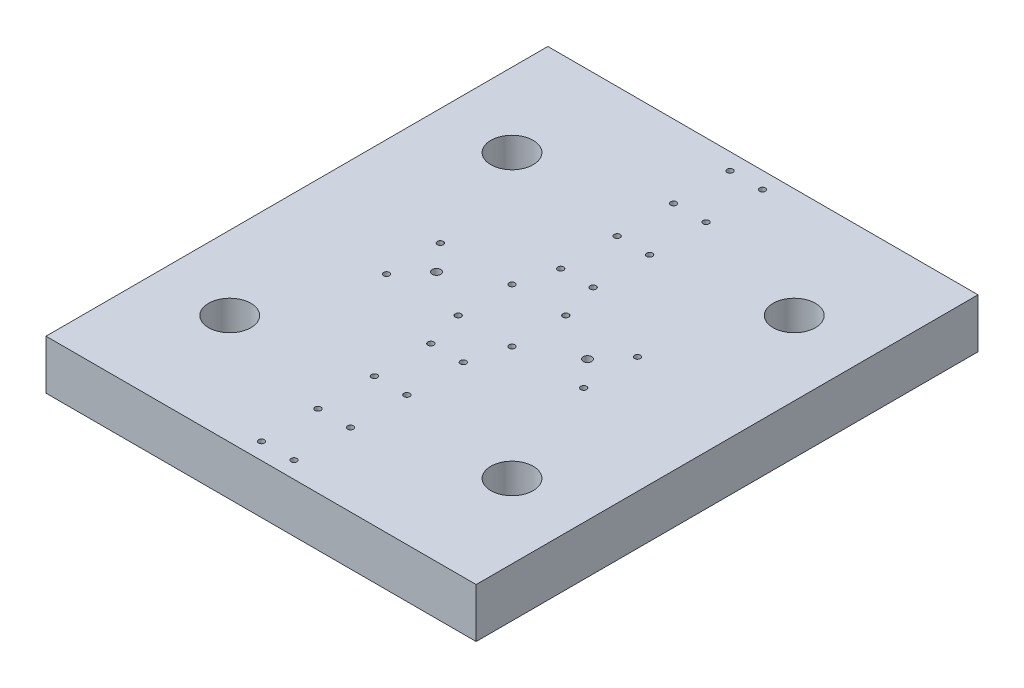
from build123d import *

# Parameters (mm, degrees)
SKETCH2_W                      = 304.8
SKETCH2_H                      = 355.6
MAINBASE_EXTRUDE_DEPTH         = 17.5
SKETCH3_R                      = 15
HOLES_POLE_DEPTH               = 36
M5X0_8_TAPPED_HOLE1_D          = 4.2
M5X0_8_TAPPED_HOLE2_D          = 4.2
M5X0_8_TAPPED_HOLE3_AT_2_COUNT = 2
M5X0_8_TAPPED_HOLE3_AT_2_PITCH = 15
M5X0_8_TAPPED_HOLE3_AT_3_COUNT = 2
M5X0_8_TAPPED_HOLE3_AT_3_PITCH = 57.008771255
M5X0_8_TAPPED_HOLE3_AT_4_COUNT = 2
M5X0_8_TAPPED_HOLE3_AT_4_PITCH = 55
M5X0_8_TAPPED_HOLE3_AT_5_COUNT = 2
M5X0_8_TAPPED_HOLE3_AT_5_PITCH = 115.974135047
M5X0_8_TAPPED_HOLE3_AT_6_COUNT = 2
M5X0_8_TAPPED_HOLE3_AT_6_PITCH = 115
SKETCH14_R                     = 3
CUT_EXTRUDE1_DEPTH             = 10


with BuildPart() as part:
    # Sketch2 → MainBase_Extrude (new body, symmetric)
    with BuildSketch(Plane(origin=(0, 0, 0), x_dir=(1, 0, 0), z_dir=(0, 1, 0))):
        Rectangle(SKETCH2_W, SKETCH2_H)
    extrude(amount=MAINBASE_EXTRUDE_DEPTH, both=True)

    # Sketch3 → Holes_Pole (cut, through all)
    with BuildSketch(Plane(origin=(0, 17.5, 0), x_dir=(1, 0, 0), z_dir=(0, 1, 0))):
        with Locations((-100, 100)):
            Circle(SKETCH3_R)
        with Locations((100, 100)):
            Circle(SKETCH3_R)
        with Locations((100, -100)):
            Circle(SKETCH3_R)
        with Locations((-100, -100)):
            Circle(SKETCH3_R)
    extrude(amount=-HOLES_POLE_DEPTH, mode=Mode.SUBTRACT)

    # M5x0.8 Tapped Hole1 (through all)
    with Locations(Plane(origin=(0, 17.5, 0), x_dir=(1, 0, 0), z_dir=(0, 1, 0))):
        with Locations((-69.85, 19.05), (-19.05, 19.05), (-19.05, -19.05), (-69.85, -19.05), (19.05, 19.05), (19.05, -19.05), (69.85, -19.05), (69.85, 19.05)):
            Hole(M5X0_8_TAPPED_HOLE1_D / 2)

    # M5x0.8 Tapped Hole2 (through all)
    with Locations(Plane(origin=(0, 17.5, 0), x_dir=(1, 0, 0), z_dir=(0, 1, 0))):
        with Locations((-11.5, -45.9918251), (11.5, -45.9918251), (11.5, -85.9918251), (-11.5, -85.9918251), (-11.5, -125.9918251), (11.5, -125.9918251), (-11.5, -165.9918251), (11.5, -165.9918251)):
            m5x0_8_tapped_hole2 = Hole(M5X0_8_TAPPED_HOLE2_D / 2)

    # Mirror1: M5x0.8 Tapped Hole2 across plane
    add(m5x0_8_tapped_hole2.mirror(Plane.XY), mode=Mode.SUBTRACT)

    # Sketch12 → M5x0.8 Tapped Hole3 (revolve, cut)
    with BuildSketch(Plane(origin=(-64.5, -17.5, -142.5), x_dir=(0, 0, -1), z_dir=(1, 0, 0))):
        Polygon((0, 0), (0, 13.6618073), (2.1, 12.4), (2.1, 0), align=None)
    m5x0_8_tapped_hole3 = revolve(axis=Axis((-64.5, -23.85, -142.5), (0, 1, 0)), mode=Mode.SUBTRACT)

    # M5x0.8 Tapped Hole3 at 2: M5x0.8 Tapped Hole3 ×2
    with Locations(*[(i * M5X0_8_TAPPED_HOLE3_AT_2_PITCH, 0, 0) for i in range(1, M5X0_8_TAPPED_HOLE3_AT_2_COUNT)]):
        add(m5x0_8_tapped_hole3, mode=Mode.SUBTRACT)

    # M5x0.8 Tapped Hole3 at 3: M5x0.8 Tapped Hole3 ×2
    with Locations(*[Vector(0.263117406, 0, 0.964763821) * (i * M5X0_8_TAPPED_HOLE3_AT_3_PITCH) for i in range(1, M5X0_8_TAPPED_HOLE3_AT_3_COUNT)]):
        add(m5x0_8_tapped_hole3, mode=Mode.SUBTRACT)

    # M5x0.8 Tapped Hole3 at 4: M5x0.8 Tapped Hole3 ×2
    with Locations(*[(0, 0, i * M5X0_8_TAPPED_HOLE3_AT_4_PITCH) for i in range(1, M5X0_8_TAPPED_HOLE3_AT_4_COUNT)]):
        add(m5x0_8_tapped_hole3, mode=Mode.SUBTRACT)

    # M5x0.8 Tapped Hole3 at 5: M5x0.8 Tapped Hole3 ×2
    with Locations(*[Vector(0.129339184, 0, 0.991600411) * (i * M5X0_8_TAPPED_HOLE3_AT_5_PITCH) for i in range(1, M5X0_8_TAPPED_HOLE3_AT_5_COUNT)]):
        add(m5x0_8_tapped_hole3, mode=Mode.SUBTRACT)

    # M5x0.8 Tapped Hole3 at 6: M5x0.8 Tapped Hole3 ×2
    with Locations(*[(0, 0, i * M5X0_8_TAPPED_HOLE3_AT_6_PITCH) for i in range(1, M5X0_8_TAPPED_HOLE3_AT_6_COUNT)]):
        add(m5x0_8_tapped_hole3, mode=Mode.SUBTRACT)

    # Mirror2: M5x0.8 Tapped Hole3 across plane
    add(m5x0_8_tapped_hole3.mirror(Plane.XY), mode=Mode.SUBTRACT)

    # Mirror2 copy 1 sketch → Mirror2 copy 1 (revolve, cut)
    with BuildSketch(Plane(origin=(-49.5, -17.5, 142.5), x_dir=(0, 0, 1), z_dir=(1, 0, 0))):
        Polygon((0, 0), (0, -13.6618073), (2.1, -12.4), (2.1, 0), align=None)
    revolve(axis=Axis((-49.5, -23.85, 142.5), (0, -1, 0)), mode=Mode.SUBTRACT)

    # Mirror2 copy 2 sketch → Mirror2 copy 2 (revolve, cut)
    with BuildSketch(Plane(origin=(-49.5, -17.5, 87.5), x_dir=(0, 0, 1), z_dir=(1, 0, 0))):
        Polygon((0, 0), (0, -13.6618073), (2.1, -12.4), (2.1, 0), align=None)
    revolve(axis=Axis((-49.5, -23.85, 87.5), (0, -1, 0)), mode=Mode.SUBTRACT)

    # Mirror2 copy 3 sketch → Mirror2 copy 3 (revolve, cut)
    with BuildSketch(Plane(origin=(-64.5, -17.5, 87.5), x_dir=(0, 0, 1), z_dir=(1, 0, 0))):
        Polygon((0, 0), (0, -13.6618073), (2.1, -12.4), (2.1, 0), align=None)
    revolve(axis=Axis((-64.5, -23.85, 87.5), (0, -1, 0)), mode=Mode.SUBTRACT)

    # Mirror2 copy 4 sketch → Mirror2 copy 4 (revolve, cut)
    with BuildSketch(Plane(origin=(-49.5, -17.5, 27.5), x_dir=(0, 0, 1), z_dir=(1, 0, 0))):
        Polygon((0, 0), (0, -13.6618073), (2.1, -12.4), (2.1, 0), align=None)
    revolve(axis=Axis((-49.5, -23.85, 27.5), (0, -1, 0)), mode=Mode.SUBTRACT)

    # Mirror2 copy 5 sketch → Mirror2 copy 5 (revolve, cut)
    with BuildSketch(Plane(origin=(-64.5, -17.5, 27.5), x_dir=(0, 0, 1), z_dir=(1, 0, 0))):
        Polygon((0, 0), (0, -13.6618073), (2.1, -12.4), (2.1, 0), align=None)
    revolve(axis=Axis((-64.5, -23.85, 27.5), (0, -1, 0)), mode=Mode.SUBTRACT)

    # Mirror3: M5x0.8 Tapped Hole3 across plane
    add(m5x0_8_tapped_hole3.mirror(Plane(origin=(0, 0, 0), x_dir=(0, 0, 1), z_dir=(1, 0, 0))), mode=Mode.SUBTRACT)

    # Mirror3 copy 1 sketch → Mirror3 copy 1 (revolve, cut)
    with BuildSketch(Plane(origin=(64.5, -17.5, 142.5), x_dir=(0, 0, 1), z_dir=(-1, 0, 0))):
        Polygon((0, 0), (0, 13.6618073), (2.1, 12.4), (2.1, 0), align=None)
    revolve(axis=Axis((64.5, -23.85, 142.5), (0, 1, 0)), mode=Mode.SUBTRACT)

    # Mirror3 copy 2 sketch → Mirror3 copy 2 (revolve, cut)
    with BuildSketch(Plane(origin=(49.5, -17.5, 142.5), x_dir=(0, 0, 1), z_dir=(-1, 0, 0))):
        Polygon((0, 0), (0, 13.6618073), (2.1, 12.4), (2.1, 0), align=None)
    revolve(axis=Axis((49.5, -23.85, 142.5), (0, 1, 0)), mode=Mode.SUBTRACT)

    # Mirror3 copy 3 sketch → Mirror3 copy 3 (revolve, cut)
    with BuildSketch(Plane(origin=(49.5, -17.5, 87.5), x_dir=(0, 0, 1), z_dir=(-1, 0, 0))):
        Polygon((0, 0), (0, 13.6618073), (2.1, 12.4), (2.1, 0), align=None)
    revolve(axis=Axis((49.5, -23.85, 87.5), (0, 1, 0)), mode=Mode.SUBTRACT)

    # Mirror3 copy 4 sketch → Mirror3 copy 4 (revolve, cut)
    with BuildSketch(Plane(origin=(64.5, -17.5, 87.5), x_dir=(0, 0, 1), z_dir=(-1, 0, 0))):
        Polygon((0, 0), (0, 13.6618073), (2.1, 12.4), (2.1, 0), align=None)
    revolve(axis=Axis((64.5, -23.85, 87.5), (0, 1, 0)), mode=Mode.SUBTRACT)

    # Mirror3 copy 5 sketch → Mirror3 copy 5 (revolve, cut)
    with BuildSketch(Plane(origin=(49.5, -17.5, 27.5), x_dir=(0, 0, 1), z_dir=(-1, 0, 0))):
        Polygon((0, 0), (0, 13.6618073), (2.1, 12.4), (2.1, 0), align=None)
    revolve(axis=Axis((49.5, -23.85, 27.5), (0, 1, 0)), mode=Mode.SUBTRACT)

    # Mirror3 copy 6 sketch → Mirror3 copy 6 (revolve, cut)
    with BuildSketch(Plane(origin=(64.5, -17.5, 27.5), x_dir=(0, 0, 1), z_dir=(-1, 0, 0))):
        Polygon((0, 0), (0, 13.6618073), (2.1, 12.4), (2.1, 0), align=None)
    revolve(axis=Axis((64.5, -23.85, 27.5), (0, 1, 0)), mode=Mode.SUBTRACT)

    # Mirror3 copy 7 sketch → Mirror3 copy 7 (revolve, cut)
    with BuildSketch(Plane(origin=(49.5, -17.5, -142.5), x_dir=(0, 0, -1), z_dir=(-1, 0, 0))):
        Polygon((0, 0), (0, -13.6618073), (2.1, -12.4), (2.1, 0), align=None)
    revolve(axis=Axis((49.5, -23.85, -142.5), (0, -1, 0)), mode=Mode.SUBTRACT)

    # Mirror3 copy 8 sketch → Mirror3 copy 8 (revolve, cut)
    with BuildSketch(Plane(origin=(49.5, -17.5, -87.5), x_dir=(0, 0, -1), z_dir=(-1, 0, 0))):
        Polygon((0, 0), (0, -13.6618073), (2.1, -12.4), (2.1, 0), align=None)
    revolve(axis=Axis((49.5, -23.85, -87.5), (0, -1, 0)), mode=Mode.SUBTRACT)

    # Mirror3 copy 9 sketch → Mirror3 copy 9 (revolve, cut)
    with BuildSketch(Plane(origin=(64.5, -17.5, -87.5), x_dir=(0, 0, -1), z_dir=(-1, 0, 0))):
        Polygon((0, 0), (0, -13.6618073), (2.1, -12.4), (2.1, 0), align=None)
    revolve(axis=Axis((64.5, -23.85, -87.5), (0, -1, 0)), mode=Mode.SUBTRACT)

    # Mirror3 copy 10 sketch → Mirror3 copy 10 (revolve, cut)
    with BuildSketch(Plane(origin=(49.5, -17.5, -27.5), x_dir=(0, 0, -1), z_dir=(-1, 0, 0))):
        Polygon((0, 0), (0, -13.6618073), (2.1, -12.4), (2.1, 0), align=None)
    revolve(axis=Axis((49.5, -23.85, -27.5), (0, -1, 0)), mode=Mode.SUBTRACT)

    # Mirror3 copy 11 sketch → Mirror3 copy 11 (revolve, cut)
    with BuildSketch(Plane(origin=(64.5, -17.5, -27.5), x_dir=(0, 0, -1), z_dir=(-1, 0, 0))):
        Polygon((0, 0), (0, -13.6618073), (2.1, -12.4), (2.1, 0), align=None)
    revolve(axis=Axis((64.5, -23.85, -27.5), (0, -1, 0)), mode=Mode.SUBTRACT)

    # Sketch14 → Cut-Extrude1 (cut)
    with BuildSketch(Plane(origin=(0, 17.5, 0), x_dir=(1, 0, 0), z_dir=(0, 1, 0))):
        with Locations((53.5, 0)):
            Circle(SKETCH14_R)
    cut_extrude1 = extrude(amount=-CUT_EXTRUDE1_DEPTH, mode=Mode.SUBTRACT)

    # Mirror4: Cut-Extrude1 across plane
    add(cut_extrude1.mirror(Plane(origin=(0, 0, 0), x_dir=(0, 0, 1), z_dir=(1, 0, 0))), mode=Mode.SUBTRACT)


solid = part.part
